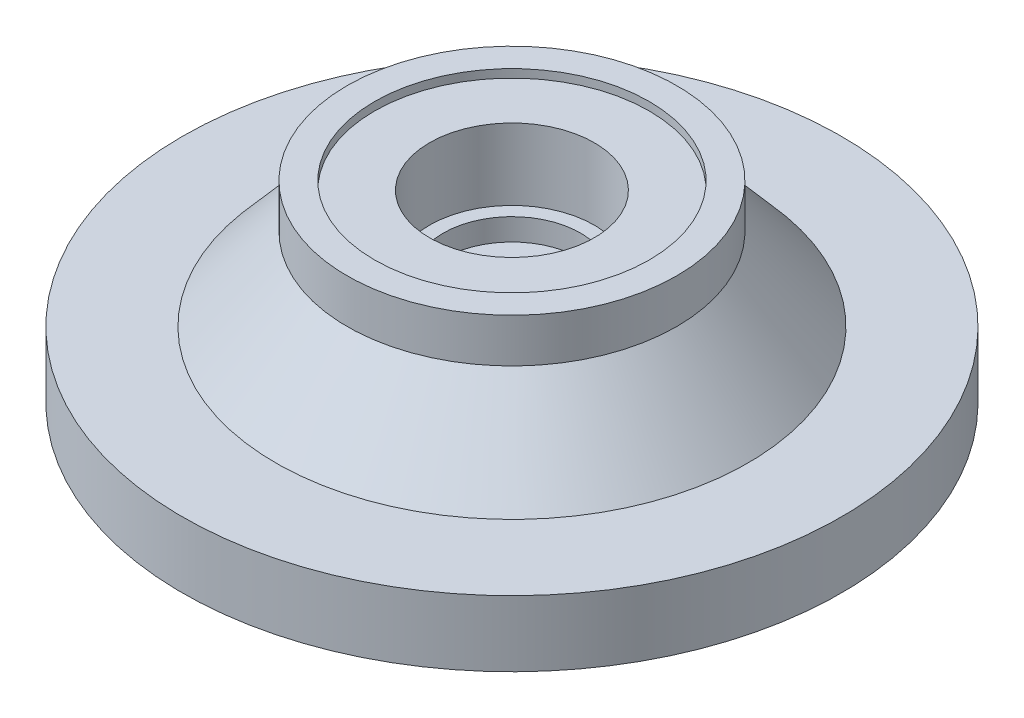
from build123d import *

# Parameters (mm, degrees)
CROQUIS2_R            = 43
CORTAR_EXTRUIR1_DEPTH = 2
CROQUIS4_R            = 40
CORTAR_EXTRUIR2_DEPTH = 3
CROQUIS6_R            = 30
CORTAR_EXTRUIR3_DEPTH = 8.5
CROQUIS8_R            = 30
CORTAR_EXTRUIR4_DEPTH = 1
CROQUIS9_R            = 25
CORTAR_EXTRUIR5_DEPTH = 1.5
CROQUIS10_R           = 15
CORTAR_EXTRUIR6_DEPTH = 13
CROQUIS11_R           = 12.5
CORTAR_EXTRUIR7_DEPTH = 18.5
CROQUIS12_R           = 9
CORTAR_EXTRUIR8_DEPTH = 22.5


with BuildPart() as part:
    # Croquis1 → Revolución1 (revolve)
    with BuildSketch(Plane.XY):
        Polygon((0, 0), (60, 0), (60, 12), (43, 12), (30, 27), (30, 35), (0, 35), align=None)
    revolve(axis=Axis((0, 35, 0), (0, -1, 0)))

    # Croquis2 → Cortar-Extruir1 (cut)
    with BuildSketch(Plane.XZ):
        Circle(CROQUIS2_R)
    extrude(amount=-CORTAR_EXTRUIR1_DEPTH, mode=Mode.SUBTRACT)

    # Croquis4 → Cortar-Extruir2 (cut)
    with BuildSketch(Plane.XZ.offset(-2)):
        Circle(CROQUIS4_R)
    extrude(amount=-CORTAR_EXTRUIR2_DEPTH, mode=Mode.SUBTRACT)

    # Croquis5 → Revolución2 (revolve)
    with BuildSketch(Plane.XY):
        Polygon((-40, 2), (-43, 0), (-43, 2), align=None)
    revolve(axis=Axis((0, 0, 0), (0, 1, 0)))

    # Croquis6 → Cortar-Extruir3 (cut)
    with BuildSketch(Plane.XZ.offset(-5)):
        Circle(CROQUIS6_R)
    extrude(amount=-CORTAR_EXTRUIR3_DEPTH, mode=Mode.SUBTRACT)

    # Croquis7 → Cortar-Revolución1 (revolve, cut)
    with BuildSketch(Plane.XY):
        Polygon((-40, 5), (-30, 5), (-30, 13.5), align=None)
    revolve(axis=Axis((0, 0, 0), (0, 1, 0)), mode=Mode.SUBTRACT)

    # Croquis8 → Cortar-Extruir4 (cut)
    with BuildSketch(Plane.XZ.offset(-13.5)):
        Circle(CROQUIS8_R)
    extrude(amount=-CORTAR_EXTRUIR4_DEPTH, mode=Mode.SUBTRACT)

    # Croquis9 → Cortar-Extruir5 (cut)
    with BuildSketch(Plane(origin=(0, 35, 0), x_dir=(1, 0, 0), z_dir=(0, 1, 0))):
        Circle(CROQUIS9_R)
    extrude(amount=-CORTAR_EXTRUIR5_DEPTH, mode=Mode.SUBTRACT)

    # Croquis10 → Cortar-Extruir6 (cut)
    with BuildSketch(Plane(origin=(0, 33.5, 0), x_dir=(1, 0, 0), z_dir=(0, 1, 0))):
        Circle(CROQUIS10_R)
    extrude(amount=-CORTAR_EXTRUIR6_DEPTH, mode=Mode.SUBTRACT)

    # Croquis11 → Cortar-Extruir7 (cut)
    with BuildSketch(Plane(origin=(0, 35, 0), x_dir=(1, 0, 0), z_dir=(0, 1, 0))):
        Circle(CROQUIS11_R)
    extrude(amount=-CORTAR_EXTRUIR7_DEPTH, mode=Mode.SUBTRACT)

    # Croquis12 → Cortar-Extruir8 (cut)
    with BuildSketch(Plane(origin=(0, 35, 0), x_dir=(1, 0, 0), z_dir=(0, 1, 0))):
        Circle(CROQUIS12_R)
    extrude(amount=-CORTAR_EXTRUIR8_DEPTH, mode=Mode.SUBTRACT)


solid = part.part
